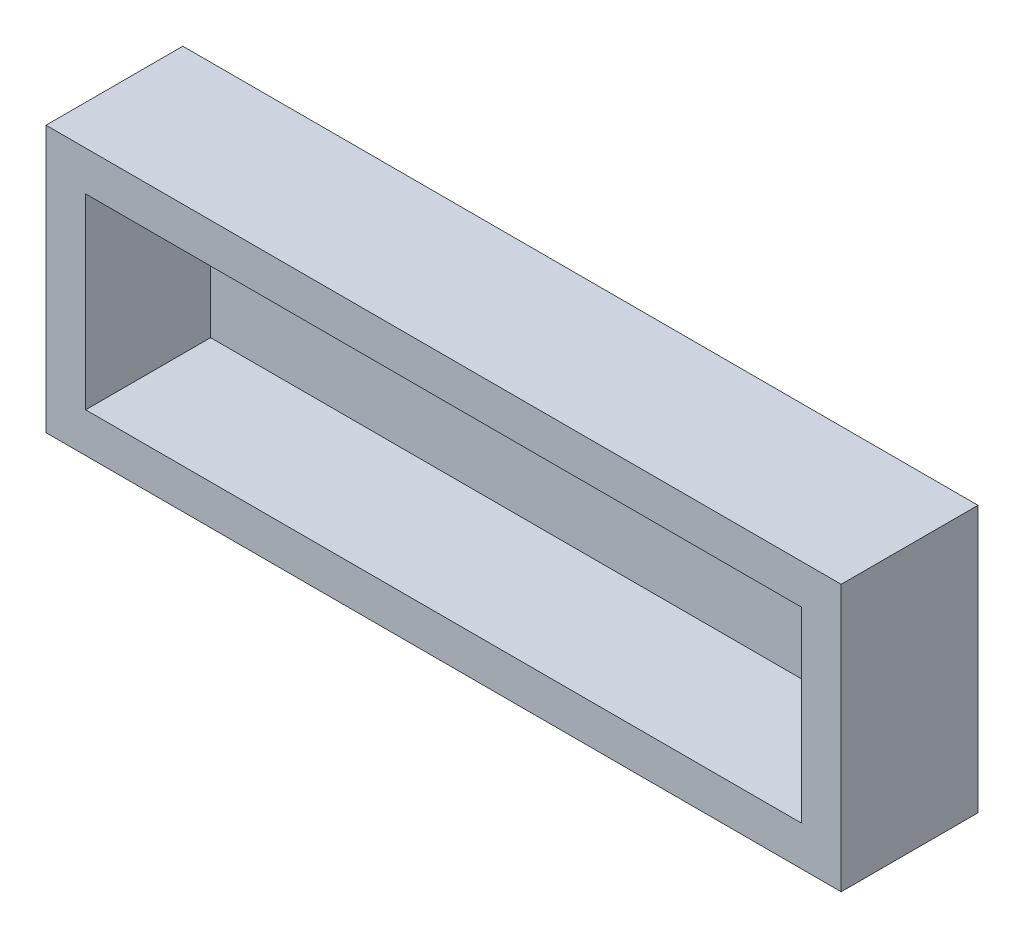
from build123d import *

# Parameters (mm, degrees)
SKETCH_1_W                 = 200.502
SKETCH_1_H                 = 67.152
EXTRUDE_2_DEPTH            = 34.5
SHELL_3_T                  = -3
SHELL_3_THICKNESS_2_FACE_W = 194.502
SHELL_3_THICKNESS_2_FACE_H = 31.5
SHELL_3_THICKNESS_2_DEPTH  = 7
SHELL_3_THICKNESS_3_FACE_W = 31.5
SHELL_3_THICKNESS_3_FACE_H = 54.152
SHELL_3_THICKNESS_3_DEPTH  = 7
SHELL_3_THICKNESS_4_FACE_W = 31.5
SHELL_3_THICKNESS_4_FACE_H = 54.152
SHELL_3_THICKNESS_4_DEPTH  = 7
SHELL_3_THICKNESS_5_FACE_W = 180.502
SHELL_3_THICKNESS_5_FACE_H = 31.5
SHELL_3_THICKNESS_5_DEPTH  = 7


with BuildPart() as part:
    # 草图1 → 凸台-拉伸2 (new body)
    with BuildSketch(Plane.XY):
        Rectangle(SKETCH_1_W, SKETCH_1_H)
    extrude(amount=EXTRUDE_2_DEPTH)

    # 抽壳3
    shell_3_openings = [part.faces().sort_by_distance(p)[0] for p in [
        (0, 0, 34.5),
    ]]
    offset(amount=SHELL_3_T, openings=shell_3_openings, kind=Kind.INTERSECTION)

    # 抽壳3 thickness 2 face (on inner face of the shell) → 抽壳3 thickness 2 (add)
    with BuildSketch(Plane(origin=(0, 30.576, 18.75), x_dir=(1, 0, 0), z_dir=(0, 1, 0))):
        Rectangle(SHELL_3_THICKNESS_2_FACE_W, SHELL_3_THICKNESS_2_FACE_H)
    extrude(amount=-SHELL_3_THICKNESS_2_DEPTH)

    # 抽壳3 thickness 3 face (on inner face of the shell) → 抽壳3 thickness 3 (add)
    with BuildSketch(Plane(origin=(97.251, -3.5, 18.75), x_dir=(0, 0, 1), z_dir=(1, 0, 0))):
        Rectangle(SHELL_3_THICKNESS_3_FACE_W, SHELL_3_THICKNESS_3_FACE_H)
    extrude(amount=-SHELL_3_THICKNESS_3_DEPTH)

    # 抽壳3 thickness 4 face (on inner face of the shell) → 抽壳3 thickness 4 (add)
    with BuildSketch(Plane(origin=(-97.251, -3.5, 18.75), x_dir=(0, 0, -1), z_dir=(-1, 0, 0))):
        Rectangle(SHELL_3_THICKNESS_4_FACE_W, SHELL_3_THICKNESS_4_FACE_H)
    extrude(amount=-SHELL_3_THICKNESS_4_DEPTH)

    # 抽壳3 thickness 5 face (on inner face of the shell) → 抽壳3 thickness 5 (add)
    with BuildSketch(Plane(origin=(0, -30.576, 18.75), x_dir=(-1, 0, 0), z_dir=(0, -1, 0))):
        Rectangle(SHELL_3_THICKNESS_5_FACE_W, SHELL_3_THICKNESS_5_FACE_H)
    extrude(amount=-SHELL_3_THICKNESS_5_DEPTH)


solid = part.part
